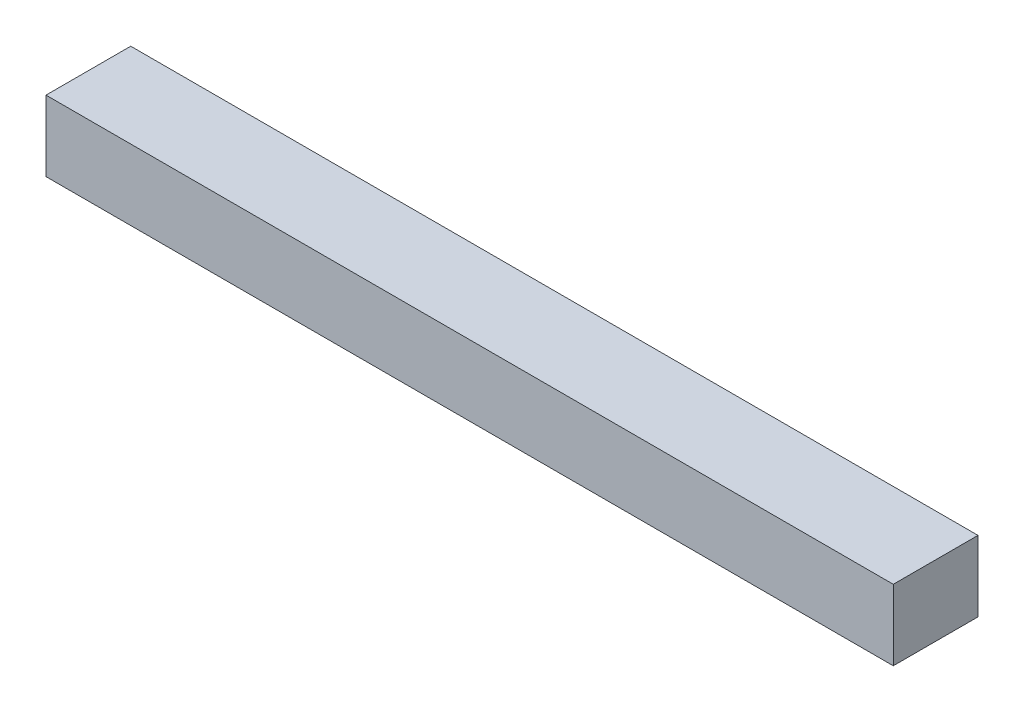
from build123d import *

# Parameters (mm, degrees)
SKETCH_2_W      = 30
SKETCH_2_H      = 25
EXTRUDE_1_DEPTH = 300


with BuildPart() as part:
    # Эскиз2 → Бобышка-Вытянуть1 (new body)
    with BuildSketch(Plane(origin=(0, 0, 0), x_dir=(0, 0, -1), z_dir=(1, 0, 0))):
        Rectangle(SKETCH_2_W, SKETCH_2_H)
    extrude(amount=EXTRUDE_1_DEPTH)


solid = part.part
